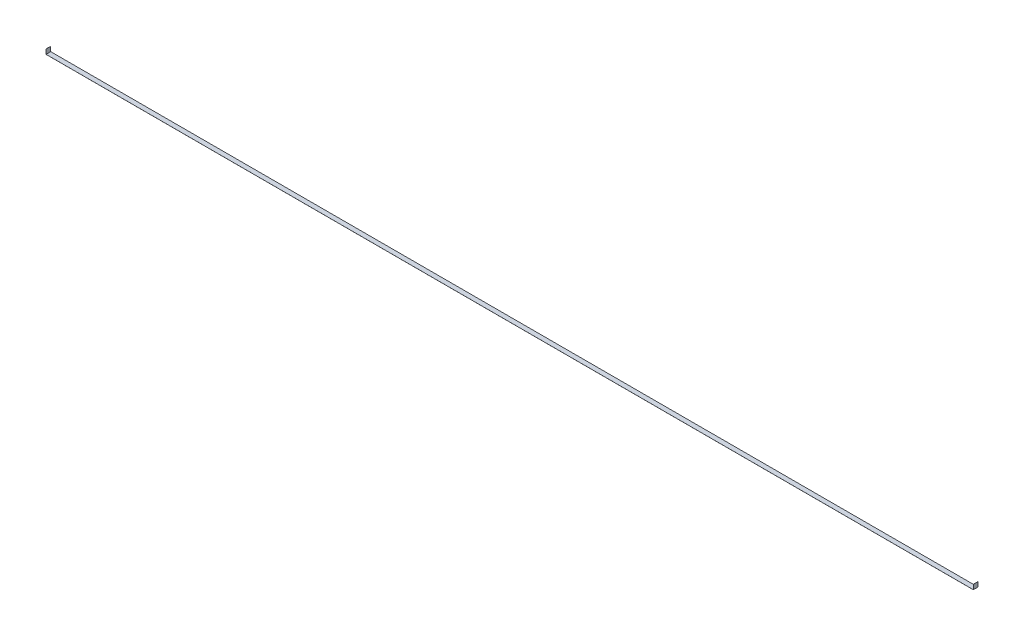
from build123d import *

# Parameters (mm, degrees)
EXTRUDE_THIN1_DEPTH = 12.7


with BuildPart() as part:
    # Sketch1 → Extrude-Thin1 (new body, symmetric)
    with BuildSketch(Plane.XY):
        Polygon((-2527.3, 25.4), (-2527.3, 0), (2527.3, 0), (2527.3, 25.4), (2527.554, 25.4), (2527.554, -0.254), (-2527.554, -0.254), (-2527.554, 25.4), align=None)
    extrude(amount=EXTRUDE_THIN1_DEPTH, both=True)


solid = part.part
